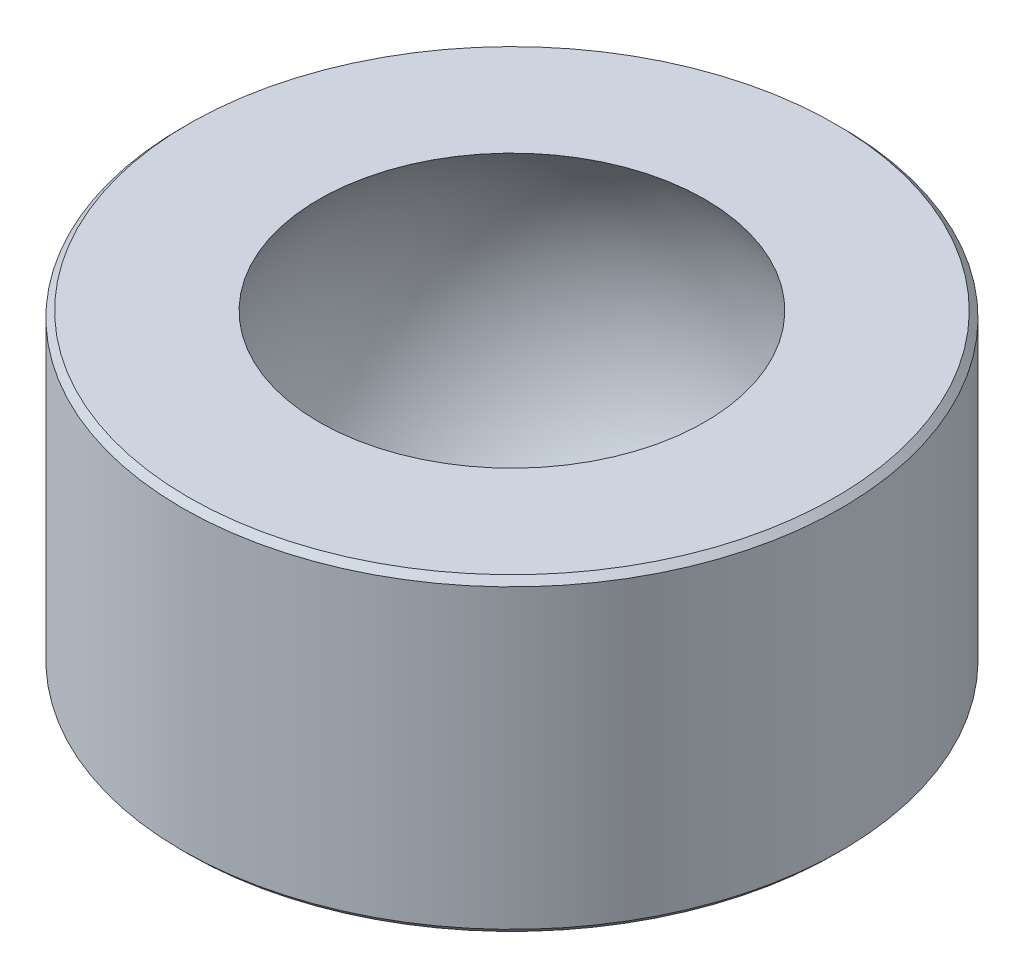
from build123d import *

# Parameters (mm, degrees)
SKETCH1_R           = 4
SKETCH1_R_2         = 2
BOSS_EXTRUDE1_DEPTH = 1.875
CHAMFER1_SIZE       = 0.075


with BuildPart() as part:
    # Sketch1 → Boss-Extrude1 (new body, symmetric)
    with BuildSketch(Plane(origin=(0, 0, 0), x_dir=(1, 0, 0), z_dir=(0, 1, 0))):
        Circle(SKETCH1_R)
        Circle(SKETCH1_R_2, mode=Mode.SUBTRACT)
    extrude(amount=BOSS_EXTRUDE1_DEPTH, both=True)


with BuildPart() as body_2:
    # Sketch2 → Revolve1 (revolve)
    with BuildSketch(Plane(origin=(0, 0, 0), x_dir=(1, 0, 0), z_dir=(0, 1, 0))):
        with BuildLine():
            Line((0, 3), (0, -3))
            ThreePointArc((0, -3), (-3, 0), (0, 3))
        make_face()
    revolve(axis=Axis((0, 0, -3), (0, 0, 1)))


with BuildPart() as part_1:
    add(part.part)

    # Combine1: cut body 2
    add(body_2.part, mode=Mode.SUBTRACT)

    # Chamfer1
    chamfer1_edges = [part_1.edges().sort_by_distance(p)[0] for p in [
        (-4, -1.875, 0),
        (-4, 1.875, 0),
    ]]
    chamfer(chamfer1_edges, length=CHAMFER1_SIZE)


solid = part_1.part
